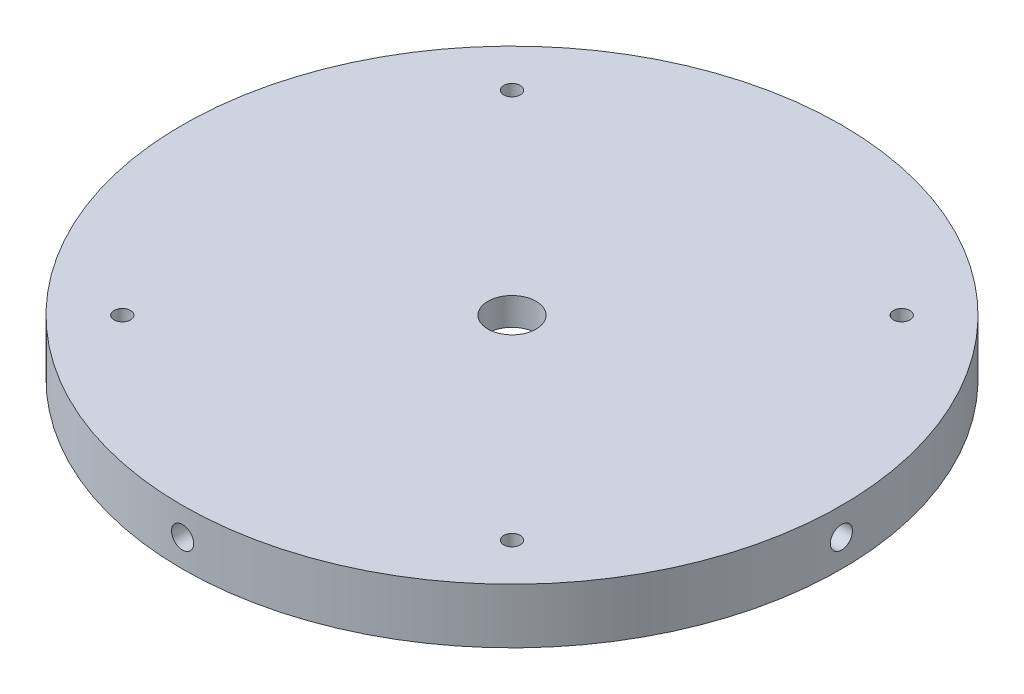
from build123d import *

# Parameters (mm, degrees)
SKETCH2_R                  = 75.946
BOSS_EXTRUDE1_DEPTH        = 12.7
SKETCH3_R                  = 5.55625
CUT_EXTRUDE1_DEPTH         = 1
CUT_EXTRUDE1_DEPTH_BACK    = 13.7
CIRPATTERN2_COUNT          = 4
CIRPATTERN2_ANGLE          = 270
SKETCH11_R                 = 69.596
CUT_EXTRUDE2_DEPTH         = 6.35
F_10_24_TAPPED_HOLE1_D     = 3.7973
F_10_24_TAPPED_HOLE1_DEPTH = 12.82954
F_10_24_TAPPED_HOLE1_TIP   = 1.140824014


with BuildPart() as part:
    # Sketch2 → Boss-Extrude1 (new body)
    with BuildSketch(Plane(origin=(0, 0, 0), x_dir=(1, 0, 0), z_dir=(0, 1, 0))):
        Circle(SKETCH2_R)
    extrude(amount=BOSS_EXTRUDE1_DEPTH)

    # Sketch3 → Cut-Extrude1 (cut, two sides)
    with BuildSketch(Plane(origin=(0, 12.7, 0), x_dir=(1, 0, 0), z_dir=(0, 1, 0))) as cut_extrude1_sk:
        Circle(SKETCH3_R)
    extrude(amount=CUT_EXTRUDE1_DEPTH, mode=Mode.SUBTRACT)
    extrude(cut_extrude1_sk.sketch, amount=-CUT_EXTRUDE1_DEPTH_BACK, mode=Mode.SUBTRACT)

    # Sketch10 → 1_4-20 Tapped Hole1 (revolve, cut)
    with BuildSketch(Plane(origin=(-76.1746, 6.35, 0), x_dir=(0, 0, 1), z_dir=(0, 1, 0))):
        Polygon((0, 0), (0, 26.933816902), (2.5527, 25.4), (2.5527, 0), align=None)
    f_1_4_20_tapped_hole1 = revolve(axis=Axis((-82.5246, 6.35, 0), (1, 0, 0)), mode=Mode.SUBTRACT)

    # CirPattern2: 1_4-20 Tapped Hole1 ×4 about axis
    cirpattern2_axis = Axis((0, 12.7, 0), (0, -1, 0))
    for i in range(1, CIRPATTERN2_COUNT):
        add(f_1_4_20_tapped_hole1.rotate(cirpattern2_axis, i * CIRPATTERN2_ANGLE / (CIRPATTERN2_COUNT - 1)), mode=Mode.SUBTRACT)

    # Sketch11 → Cut-Extrude2 (cut)
    with BuildSketch(Plane.XZ):
        Circle(SKETCH11_R)
    extrude(amount=-CUT_EXTRUDE2_DEPTH, mode=Mode.SUBTRACT)

    # 10-24 Tapped Hole1
    with Locations(Plane(origin=(0, 12.7, 0), x_dir=(1, 0, 0), z_dir=(0, 1, 0))):
        with Locations((0, 0), (44.901280605, 44.901280605), (44.901280605, -44.901280605), (-44.901280605, -44.901280605), (-44.901280605, 44.901280605)):
            Hole(F_10_24_TAPPED_HOLE1_D / 2, depth=F_10_24_TAPPED_HOLE1_DEPTH)
            with Locations((0, 0, -(F_10_24_TAPPED_HOLE1_DEPTH + F_10_24_TAPPED_HOLE1_TIP / 2))):  # 118° drill point
                Cone(0, F_10_24_TAPPED_HOLE1_D / 2, F_10_24_TAPPED_HOLE1_TIP, mode=Mode.SUBTRACT)


solid = part.part
